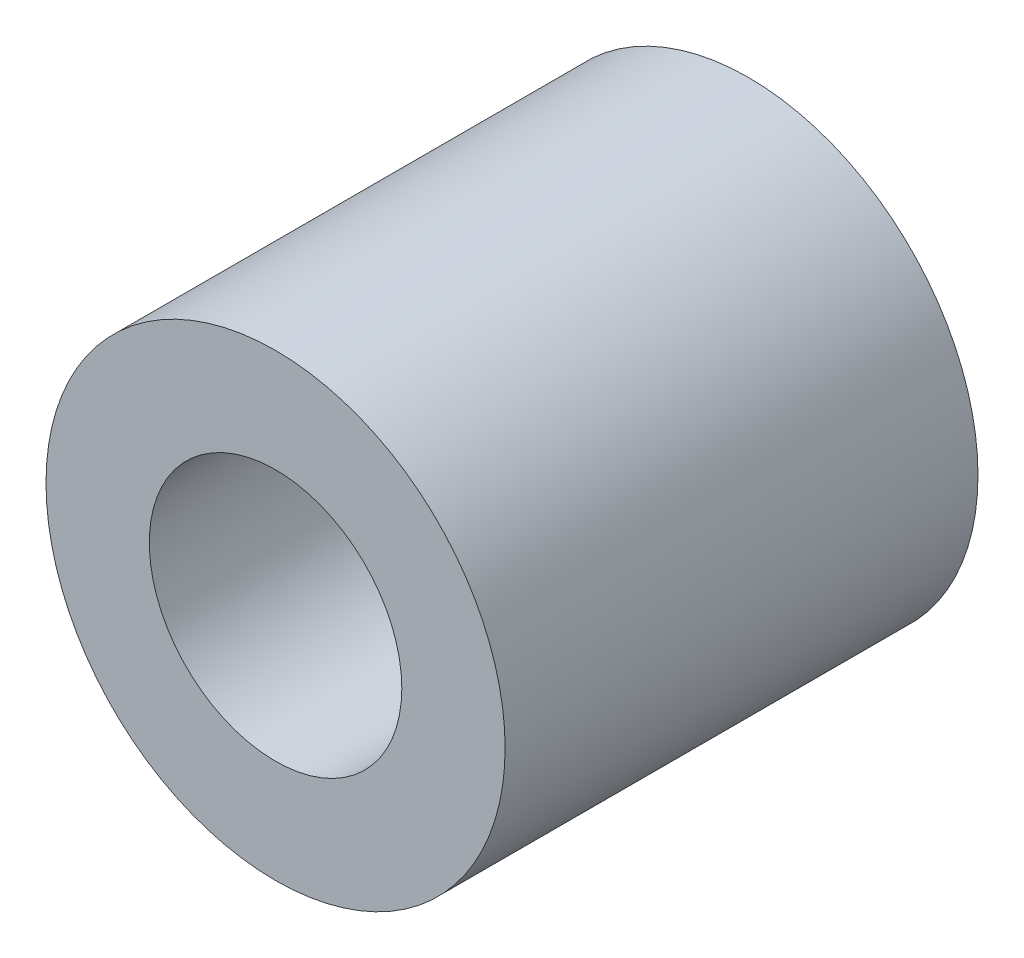
from build123d import *

# Parameters (mm, degrees)
SKETCH1_R           = 2
SKETCH1_R_2         = 1.1
BOSS_EXTRUDE1_DEPTH = 4.12


with BuildPart() as part:
    # Sketch1 → Boss-Extrude1 (new body)
    with BuildSketch(Plane.XY):
        Circle(SKETCH1_R)
        Circle(SKETCH1_R_2, mode=Mode.SUBTRACT)
    extrude(amount=BOSS_EXTRUDE1_DEPTH)


solid = part.part
